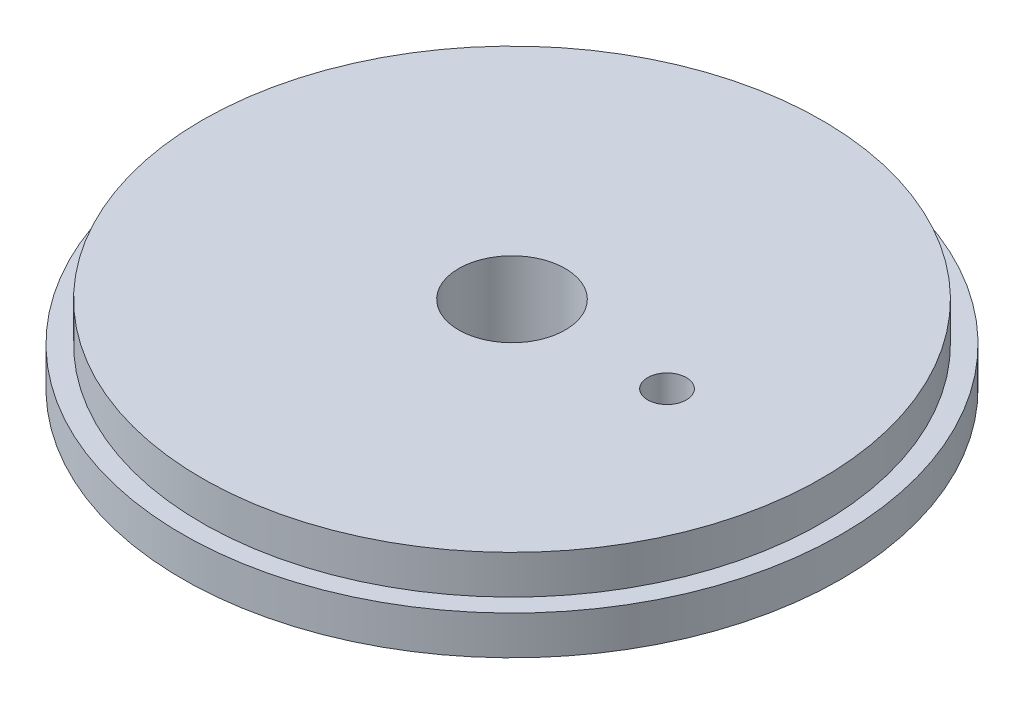
from build123d import *

# Parameters (mm, degrees)
CUT_EXTRUDE1_DEPTH      = 39.708170972
CUT_EXTRUDE1_DEPTH_BACK = 39.708170972
SKETCH2_R               = 4.365625
SKETCH2_R_2             = 1.5875
SKETCH3_R               = 3.96875
CUT_EXTRUDE2_DEPTH      = 3.175


with BuildPart() as part:
    # Sketch1 → Revolve1 (revolve)
    with BuildSketch(Plane.XY):
        Polygon((0, 0), (-27, 0), (-27, 3.175), (-25.4, 3.175), (-25.4, 6.35), (0, 6.35), align=None)
    revolve(axis=Axis((0, 6.35, 0), (0, -1, 0)))

    # Sketch2 → Cut-Extrude1 (cut, two sides: drawn at the far end of the back side and taken through both)
    with BuildSketch(Plane(origin=(0, 6.35, 0), x_dir=(1, 0, 0), z_dir=(0, 1, 0)).offset(-CUT_EXTRUDE1_DEPTH_BACK)):
        Circle(SKETCH2_R)
        with Locations((12.7, 0)):
            Circle(SKETCH2_R_2)
    extrude(amount=CUT_EXTRUDE1_DEPTH + CUT_EXTRUDE1_DEPTH_BACK, mode=Mode.SUBTRACT)

    # Sketch3 → Cut-Extrude2 (cut)
    with BuildSketch(Plane.XZ):
        with Locations((0, 12.7)):
            Circle(SKETCH3_R)
    extrude(amount=-CUT_EXTRUDE2_DEPTH, mode=Mode.SUBTRACT)


solid = part.part
